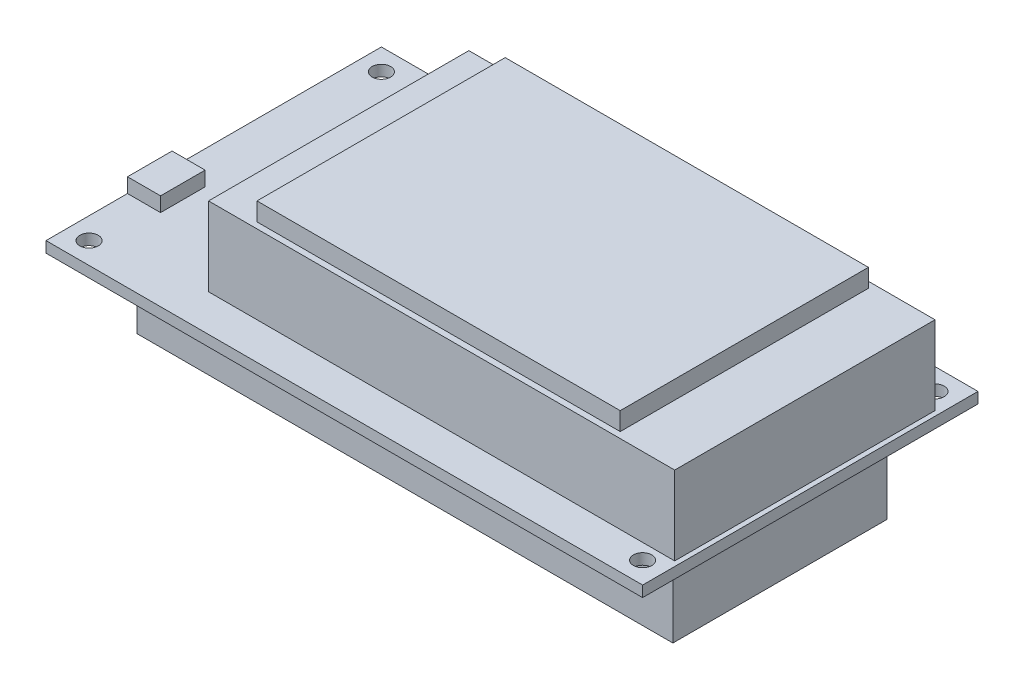
from build123d import *

# Parameters (mm, degrees)
SKETCH_1_W      = 98.55
SKETCH_1_H      = 55.4
SKETCH_1_R      = 1.524
EXTRUDE_1_DEPTH = 1.8
SKETCH_2_W      = 77
SKETCH_2_H      = 43
EXTRUDE_2_DEPTH = 13
SKETCH_3_W      = 60
SKETCH_3_H      = 41
EXTRUDE_3_DEPTH = 3
SKETCH_4_W      = 5.46
SKETCH_4_H      = 7.366
EXTRUDE_4_DEPTH = 2.4
SKETCH_5_W      = 88.55
SKETCH_5_H      = 35.4
EXTRUDE_5_DEPTH = 14


with BuildPart() as part:
    # 草图1 → 凸台-拉伸1 (new body)
    with BuildSketch(Plane(origin=(0, 0, 0), x_dir=(1, 0, 0), z_dir=(0, 1, 0))):
        with Locations((49.275, 27.7)):
            Rectangle(SKETCH_1_W, SKETCH_1_H)
        with Locations((3.556, 3.556)):
            Circle(SKETCH_1_R, mode=Mode.SUBTRACT)
        with Locations((94.996, 3.556)):
            Circle(SKETCH_1_R, mode=Mode.SUBTRACT)
        with Locations((94.996, 51.846)):
            Circle(SKETCH_1_R, mode=Mode.SUBTRACT)
        with Locations((3.556, 51.846)):
            Circle(SKETCH_1_R, mode=Mode.SUBTRACT)
    extrude(amount=EXTRUDE_1_DEPTH)

    # 草图2 → 凸台-拉伸2 (add)
    with BuildSketch(Plane(origin=(0, 1.8, 0), x_dir=(1, 0, 0), z_dir=(0, 1, 0))):
        with Locations((59.25, 27.6)):
            Rectangle(SKETCH_2_W, SKETCH_2_H)
    extrude(amount=EXTRUDE_2_DEPTH)

    # 草图3 → 凸台-拉伸3 (add)
    with BuildSketch(Plane(origin=(0, 14.8, 0), x_dir=(1, 0, 0), z_dir=(0, 1, 0))):
        with Locations((57.75, 27.6)):
            Rectangle(SKETCH_3_W, SKETCH_3_H)
    extrude(amount=EXTRUDE_3_DEPTH)

    # 草图5 → 凸台-拉伸5 (add)
    with BuildSketch(Plane.XZ):
        with Locations((49.275, -27.7)):
            Rectangle(SKETCH_5_W, SKETCH_5_H)
    extrude(amount=EXTRUDE_5_DEPTH)


with BuildPart() as body_2:
    # 草图4 → 凸台-拉伸4 (new body)
    with BuildSketch(Plane(origin=(0, 1.8, 0), x_dir=(1, 0, 0), z_dir=(0, 1, 0))):
        with Locations((2.73, 17.143)):
            Rectangle(SKETCH_4_W, SKETCH_4_H)
    extrude(amount=EXTRUDE_4_DEPTH)


solid = Compound([part.part, body_2.part])
